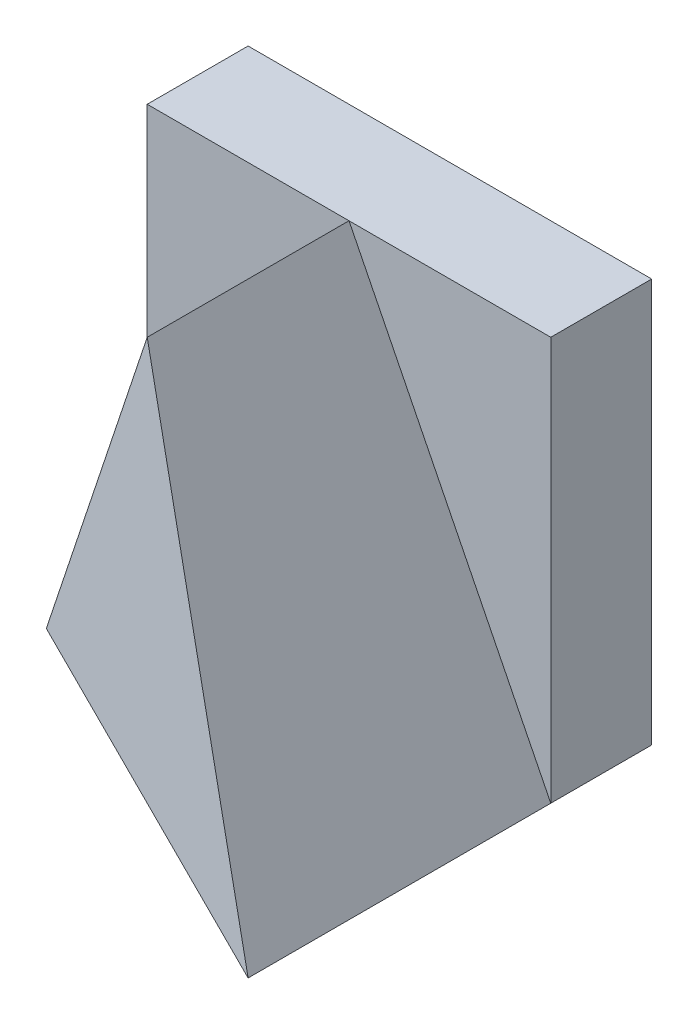
from build123d import *

# Parameters (mm, degrees)
SKETCH2_W           = 4
SKETCH2_H           = 4
BOSS_EXTRUDE1_DEPTH = 4
CUT_EXTRUDE1_DEPTH  = 3
CUT_EXTRUDE2_DEPTH  = 7


with BuildPart() as part:
    # Sketch2 → Boss-Extrude1 (new body)
    with BuildSketch(Plane(origin=(0, 0, 0), x_dir=(1, 0, 0), z_dir=(0, 1, 0))):
        Rectangle(SKETCH2_W, SKETCH2_H)
    extrude(amount=BOSS_EXTRUDE1_DEPTH)

    # Sketch3 → Cut-Extrude1 (cut)
    with BuildSketch(Plane.XY.offset(2)):
        Polygon((2, 4), (0, 4), (2, 0), align=None)
        Polygon((-2, 4), (-2, 0), (0, 4), align=None)
    extrude(amount=-CUT_EXTRUDE1_DEPTH, mode=Mode.SUBTRACT)

    # Sketch4 → Cut-Extrude2 (cut)
    with BuildSketch(Plane.XZ):
        Polygon((2, 2), (-2, 0), (-2, 2), align=None)
    extrude(amount=-CUT_EXTRUDE2_DEPTH, mode=Mode.SUBTRACT)


solid = part.part
